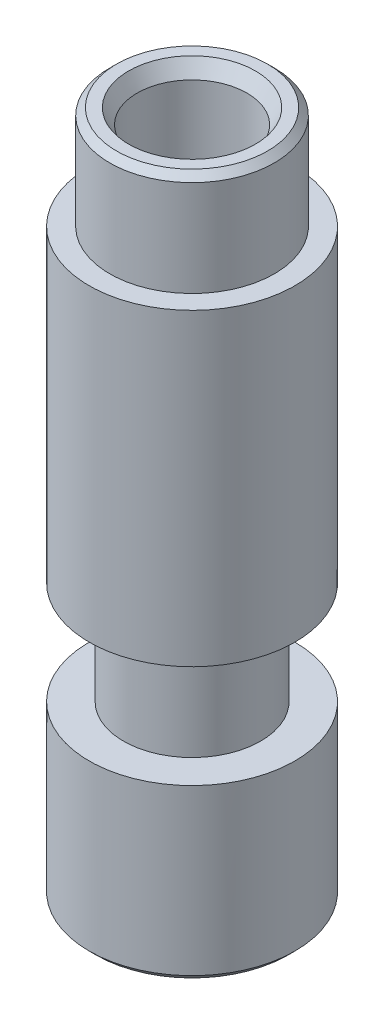
from build123d import *

# Parameters (mm, degrees)
CHAFL_N4_SIZE  = 0.2
CHAFL_N5_SIZE  = 0.25
CHAFL_N5_SIZE2 = 0.433012702


with BuildPart() as part:
    # Croquis3 → Revolución1 (revolve)
    with BuildSketch(Plane.XY):
        Polygon((-1.6, 0), (-1.6, 20), (-2.4, 20), (-2.4, 17), (-3, 17), (-3, 8), (-2, 8), (-2, 5), (-3, 5), (-3, 0), align=None)
    revolve(axis=Axis((0, 0, 0), (0, 1, 0)))

    # Chaflán4
    chafl_n4_edges = [part.edges().sort_by_distance(p)[0] for p in [
        (2.4, 20, 0),
        (3, 0, 0),
    ]]
    chamfer(chafl_n4_edges, length=CHAFL_N4_SIZE)

    # Chaflán5
    chafl_n5_edges = [part.edges().sort_by_distance(p)[0] for p in [
        (1.6, 20, 0),
    ]]
    chafl_n5_side = [part.faces().sort_by_distance(p)[0] for p in [
        (2.137774603, 20, 0),
    ]]
    chamfer(chafl_n5_edges, length=CHAFL_N5_SIZE, length2=CHAFL_N5_SIZE2, reference=chafl_n5_side[0])


solid = part.part
